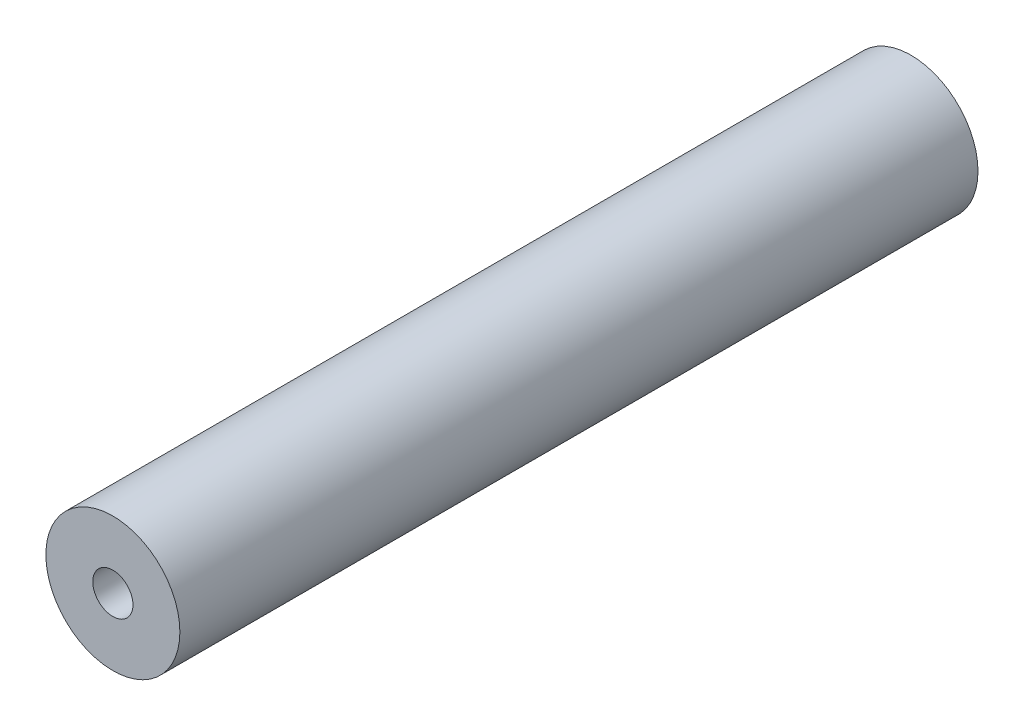
from build123d import *

# Parameters (mm, degrees)
SKETCH1_R           = 31.75
SKETCH1_R_2         = 9.525
BOSS_EXTRUDE1_DEPTH = 378.206


with BuildPart() as part:
    # Sketch1 → Boss-Extrude1 (new body)
    with BuildSketch(Plane.XY):
        Circle(SKETCH1_R)
        Circle(SKETCH1_R_2, mode=Mode.SUBTRACT)
    extrude(amount=BOSS_EXTRUDE1_DEPTH)


solid = part.part
